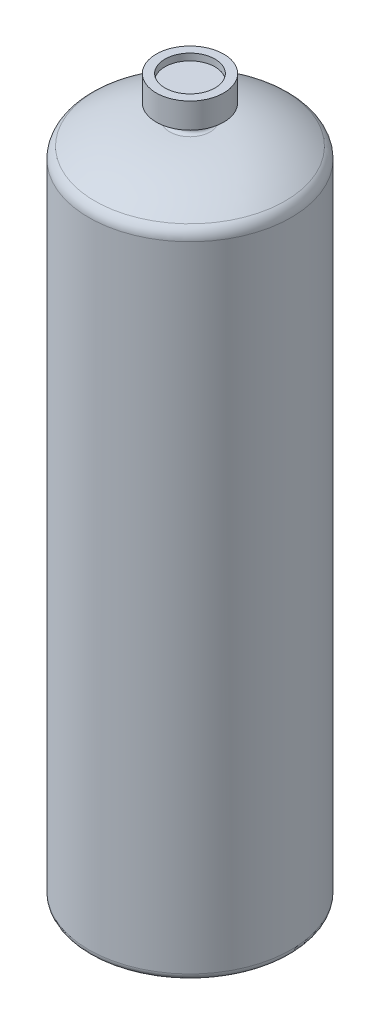
from build123d import *

# Parameters (mm, degrees)
FILLET1_R          = 2.54
SKETCH2_R          = 9.426821905
CUT_EXTRUDE1_DEPTH = 2.54


with BuildPart() as part:
    # Sketch1 → Revolve1 (revolve)
    with BuildSketch(Plane.XY):
        with BuildLine():
            Line((0, 0), (-38.1, 0))
            Line((-38.1, 0), (-38.1, 241.3))
            ThreePointArc((-38.1, 241.3), (-37.492793188, 243.708427101), (-35.816330275, 245.541100917))
            ThreePointArc((-35.816330275, 245.541100917), (-22.338916525, 251.83972175), (-7.62, 254))
            ThreePointArc((-7.62, 254), (-6.721974388, 254.371974388), (-6.35, 255.27))
            Line((-6.35, 255.27), (-6.35, 259.715))
            Line((-6.35, 259.715), (-12.7, 259.715))
            Line((-12.7, 259.715), (-12.7, 269.24))
            Line((-12.7, 269.24), (0, 269.24))
            Line((0, 269.24), (0, 0))
        make_face()
    revolve(axis=Axis((0, 0, 0), (0, 1, 0)))

    # Fillet1
    fillet1_edges = [part.edges().sort_by_distance(p)[0] for p in [
        (38.1, 0, 0),
    ]]
    fillet(fillet1_edges, radius=FILLET1_R)

    # Sketch2 → Cut-Extrude1 (cut)
    with BuildSketch(Plane(origin=(0, 269.24, 0), x_dir=(1, 0, 0), z_dir=(0, 1, 0))):
        Circle(SKETCH2_R)
    extrude(amount=-CUT_EXTRUDE1_DEPTH, mode=Mode.SUBTRACT)


solid = part.part
